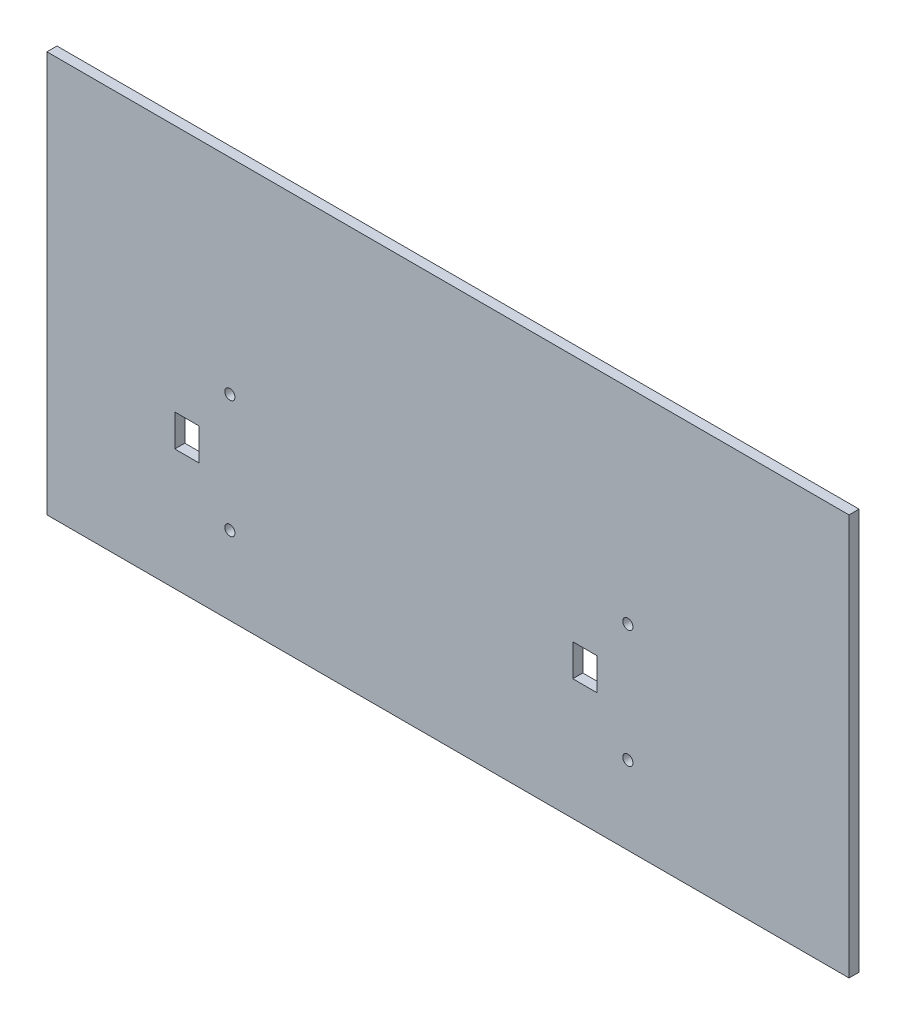
from build123d import *

# Parameters (mm, degrees)
SKETCH1_W           = 254
SKETCH1_H           = 127
BOSS_EXTRUDE1_DEPTH = 1.5875
SKETCH3_R           = 1.61
SKETCH3_W           = 7.62
SKETCH3_H           = 10.15
CUT_EXTRUDE2_DEPTH  = 5.08


with BuildPart() as part:
    # Sketch1 → Boss-Extrude1 (new body, symmetric)
    with BuildSketch(Plane.XY):
        Rectangle(SKETCH1_W, SKETCH1_H)
    extrude(amount=BOSS_EXTRUDE1_DEPTH, both=True)

    # Sketch3 → Cut-Extrude2 (cut)
    with BuildSketch(Plane(origin=(0, 0, -1.5875), x_dir=(-1, 0, 0), z_dir=(0, 0, -1))):
        with Locations((-56.955000009, -1.46)):
            Circle(SKETCH3_R)
        with Locations((-56.955000009, -38.74)):
            Circle(SKETCH3_R)
        with Locations((69.069464686, -38.74)):
            Circle(SKETCH3_R)
        with Locations((69.069464686, -1.46)):
            Circle(SKETCH3_R)
        with Locations((-43.320000018, -20.1)):
            Rectangle(SKETCH3_W, SKETCH3_H)
        with Locations((82.704464677, -20.1)):
            Rectangle(SKETCH3_W, SKETCH3_H)
    extrude(amount=-CUT_EXTRUDE2_DEPTH, mode=Mode.SUBTRACT)


solid = part.part
